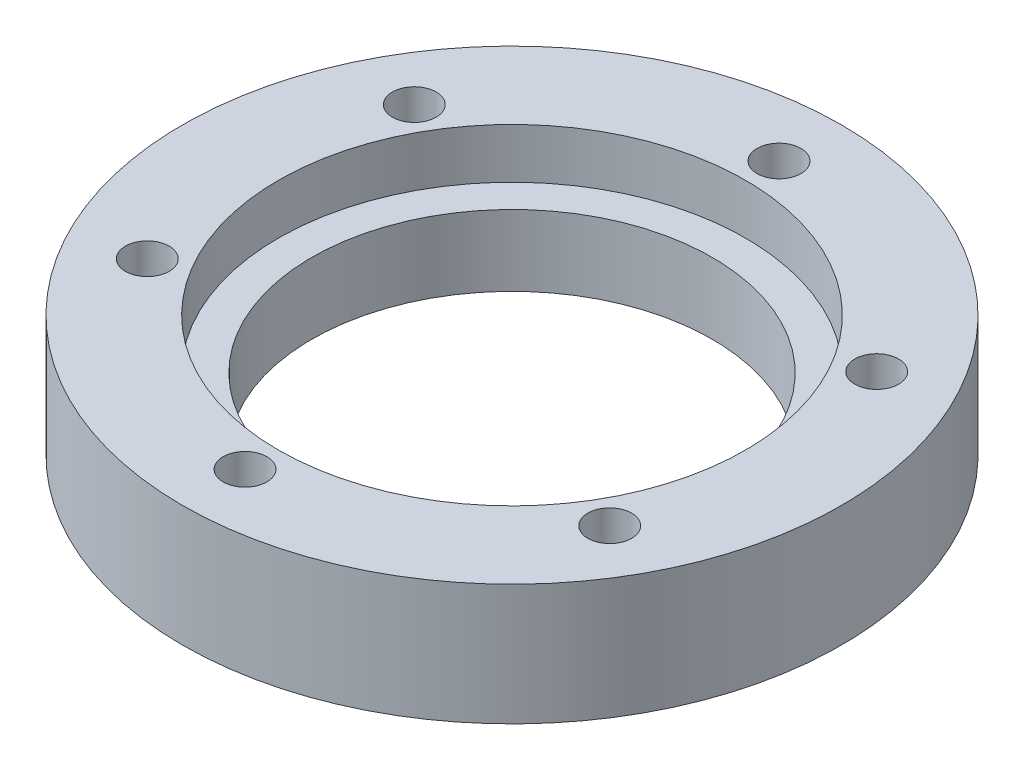
from build123d import *

# Parameters (mm, degrees)
SKETCH1_R                               = 79
BOSS_EXTRUDE1_DEPTH                     = 29
CBORE_FOR_M5_HEX_HEAD_BOLT1_D           = 96
CBORE_FOR_M5_HEX_HEAD_BOLT1_CBORE_D     = 112
CBORE_FOR_M5_HEX_HEAD_BOLT1_CBORE_DEPTH = 12
M12X1_5_TAPPED_HOLE1_D                  = 10.5
CIRPATTERN2_COUNT                       = 6


with BuildPart() as part:
    # Sketch1 → Boss-Extrude1 (new body)
    with BuildSketch(Plane(origin=(0, 0, 0), x_dir=(1, 0, 0), z_dir=(0, 1, 0))):
        Circle(SKETCH1_R)
    extrude(amount=BOSS_EXTRUDE1_DEPTH)

    # CBORE for M5 Hex Head Bolt1 (through all)
    with Locations(Plane(origin=(0, 29, 0), x_dir=(1, 0, 0), z_dir=(0, 1, 0))):
        with Locations((0, 0)):
            CounterBoreHole(CBORE_FOR_M5_HEX_HEAD_BOLT1_D / 2, CBORE_FOR_M5_HEX_HEAD_BOLT1_CBORE_D / 2, CBORE_FOR_M5_HEX_HEAD_BOLT1_CBORE_DEPTH)

    # M12x1.5 Tapped Hole1 (through all)
    with Locations(Plane(origin=(0, 29, 0), x_dir=(1, 0, 0), z_dir=(0, 1, 0))):
        with Locations((55.425625842, -32)):
            m12x1_5_tapped_hole1 = Hole(M12X1_5_TAPPED_HOLE1_D / 2)

    # CirPattern2: M12x1.5 Tapped Hole1 ×6 about axis
    cirpattern2_axis = Axis((0, 0, 0), (0, 1, 0))
    for i in range(1, CIRPATTERN2_COUNT):
        add(m12x1_5_tapped_hole1.rotate(cirpattern2_axis, i * 360 / CIRPATTERN2_COUNT), mode=Mode.SUBTRACT)


solid = part.part
